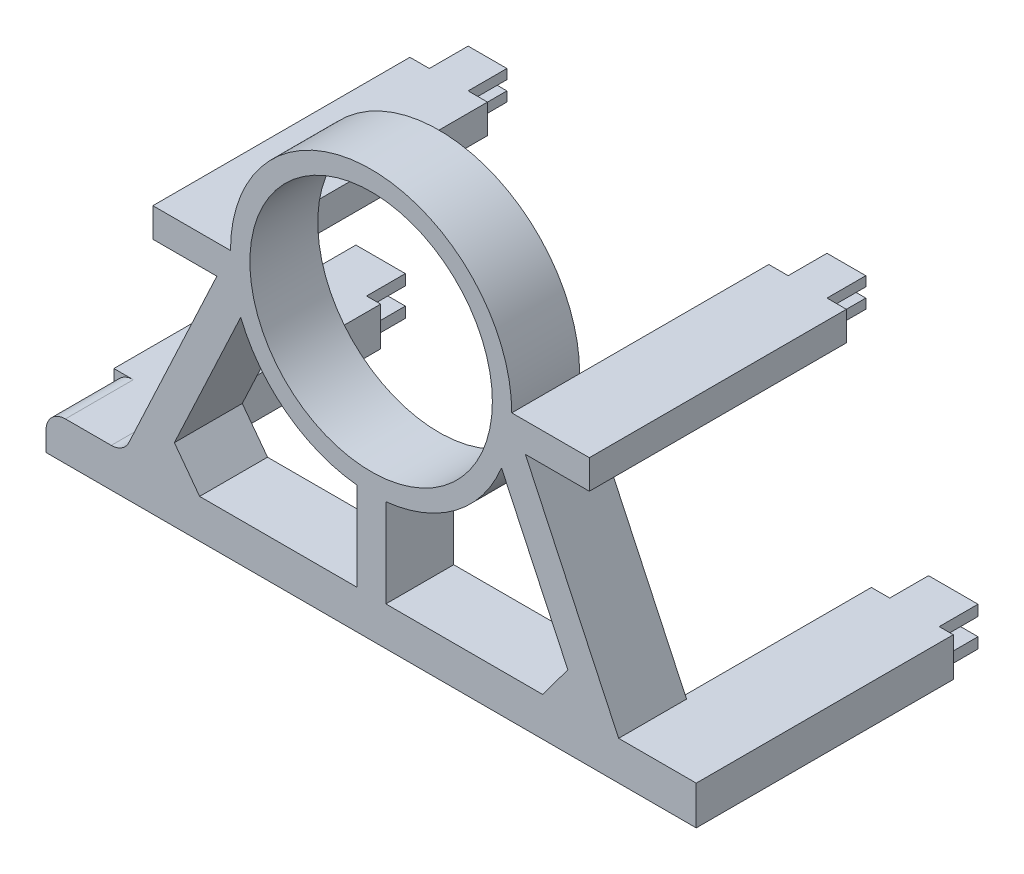
from build123d import *

# Parameters (mm, degrees)
SKETCH1_R            = 62.5
BOSS_EXTRUDE8_DEPTH  = 35
BOSS_EXTRUDE9_REACH  = 192.245
SKETCH2_W            = 15
SKETCH2_H            = 35
FILLET4_R            = 10
FILLET5_R            = 10
SKETCH10_W           = 35
SKETCH10_H           = 15
BOSS_EXTRUDE12_DEPTH = 40
SKETCH6_W            = 35
SKETCH6_H            = 15
BOSS_EXTRUDE10_DEPTH = 40
SKETCH12_W           = 42.229373335
SKETCH12_H           = 20
SKETCH12_W_2         = 40
SKETCH12_H_2         = 15
SKETCH12_W_3         = 39.995847529
BOSS_EXTRUDE13_DEPTH = 97.5
SKETCH13_W           = 20
SKETCH13_H           = 5
SKETCH13_W_2         = 25.5
SKETCH13_H_2         = 5.5
BOSS_EXTRUDE14_DEPTH = 20


with BuildPart() as part:
    # Sketch1 → Boss-Extrude8 (new body)
    with BuildSketch(Plane.XY):
        with BuildLine():
            Line((127.600917431, -117.745016448), (72.5, 0))
            ThreePointArc((72.5, 0), (0, 72.5), (-72.5, 0))
            Line((-72.5, 0), (-127.600917431, -117.745016448))
            Line((-127.600917431, -117.745016448), (-167.600917431, -117.745016448))
            Line((-167.600917431, -117.745016448), (-167.600917431, -137.745016448))
            Line((-167.600917431, -137.745016448), (167.600917431, -137.745016448))
            Line((167.600917431, -137.745016448), (167.600917431, -117.745016448))
            Line((167.600917431, -117.745016448), (127.600917431, -117.745016448))
        make_face()
        with BuildLine():
            ThreePointArc((-67.21559633, -27.171926873), (0, -72.5), (67.21559633, -27.171926873))
            Line((67.21559633, -27.171926873), (101.417450928, -100.25778678))
            Line((101.417450928, -100.25778678), (88.408256881, -117.745016448))
            Line((88.408256881, -117.745016448), (-88.408256881, -117.745016448))
            Line((-88.408256881, -117.745016448), (-101.417450928, -100.25778678))
            Line((-101.417450928, -100.25778678), (-67.21559633, -27.171926873))
        make_face(mode=Mode.SUBTRACT)
        Circle(SKETCH1_R, mode=Mode.SUBTRACT)
    extrude(amount=BOSS_EXTRUDE8_DEPTH)

    # Sketch2 → Boss-Extrude9 (add, up to next)
    with BuildSketch(Plane(origin=(0, -117.745016448, 0), x_dir=(1, 0, 0), z_dir=(0, 1, 0)), mode=Mode.PRIVATE) as boss_extrude9_sk1:
        with Locations((0.093911399, -17.5)):
            Rectangle(SKETCH2_W, SKETCH2_H)
    boss_extrude9_tool1 = extrude(boss_extrude9_sk1.sketch, amount=BOSS_EXTRUDE9_REACH, mode=Mode.PRIVATE) - part.part
    add(boss_extrude9_tool1.solids().sort_by_distance((0.093911, -117.745016, 17.5))[0])

    # Fillet4
    fillet4_edges = [part.edges().sort_by_distance(p)[0] for p in [
        (-167.600917431, -117.745016448, 17.5),
    ]]
    fillet(fillet4_edges, radius=FILLET4_R)

    # Fillet5
    fillet5_edges = [part.edges().sort_by_distance(p)[0] for p in [
        (-127.600917431, -117.745016448, 17.5),
    ]]
    fillet(fillet5_edges, radius=FILLET5_R)

    # Sketch10 → Boss-Extrude12 (add)
    with BuildSketch(Plane(origin=(-72.5, 0, 0), x_dir=(0, 0, -1), z_dir=(1, 0, 0))):
        with Locations((-17.5, -7.5)):
            Rectangle(SKETCH10_W, SKETCH10_H)
    extrude(amount=-BOSS_EXTRUDE12_DEPTH)

    # Sketch6 → Boss-Extrude10 (add)
    with BuildSketch(Plane(origin=(72.5, 0, 0), x_dir=(0, 0, -1), z_dir=(1, 0, 0))):
        with Locations((-17.5, -7.5)):
            Rectangle(SKETCH6_W, SKETCH6_H)
    extrude(amount=BOSS_EXTRUDE10_DEPTH)

    # Sketch12 → Boss-Extrude13 (add)
    with BuildSketch(Plane(origin=(0, 0, 0), x_dir=(-1, 0, 0), z_dir=(0, 0, -1))):
        with Locations((-146.486230764, -127.745016448)):
            Rectangle(SKETCH12_W, SKETCH12_H)
        with Locations((147.600917431, -127.745016448)):
            Rectangle(SKETCH12_W_2, SKETCH12_H)
        with Locations((-92.5, -7.5)):
            Rectangle(SKETCH12_W_2, SKETCH12_H_2)
        with Locations((92.502076235, -7.5)):
            Rectangle(SKETCH12_W_3, SKETCH12_H_2)
    extrude(amount=BOSS_EXTRUDE13_DEPTH)

    # Sketch13 → Boss-Extrude14 (add)
    with BuildSketch(Plane(origin=(0, 0, -97.5), x_dir=(-1, 0, 0), z_dir=(0, 0, -1))):
        with Locations((-92.5, -2.5)):
            Rectangle(SKETCH13_W, SKETCH13_H)
        with Locations((-92.5, -12.5)):
            Rectangle(SKETCH13_W, SKETCH13_H)
        with Locations((92.5, -2.5)):
            Rectangle(SKETCH13_W, SKETCH13_H)
        with Locations((92.5, -12.5)):
            Rectangle(SKETCH13_W, SKETCH13_H)
        with Locations((147.600917431, -120.495016448)):
            Rectangle(SKETCH13_W_2, SKETCH13_H_2)
        with Locations((147.600917431, -134.995016448)):
            Rectangle(SKETCH13_W_2, SKETCH13_H_2)
        with Locations((-147.600917431, -120.495016448)):
            Rectangle(SKETCH13_W_2, SKETCH13_H_2)
        with Locations((-147.600917431, -134.995016448)):
            Rectangle(SKETCH13_W_2, SKETCH13_H_2)
    extrude(amount=BOSS_EXTRUDE14_DEPTH)


solid = part.part
